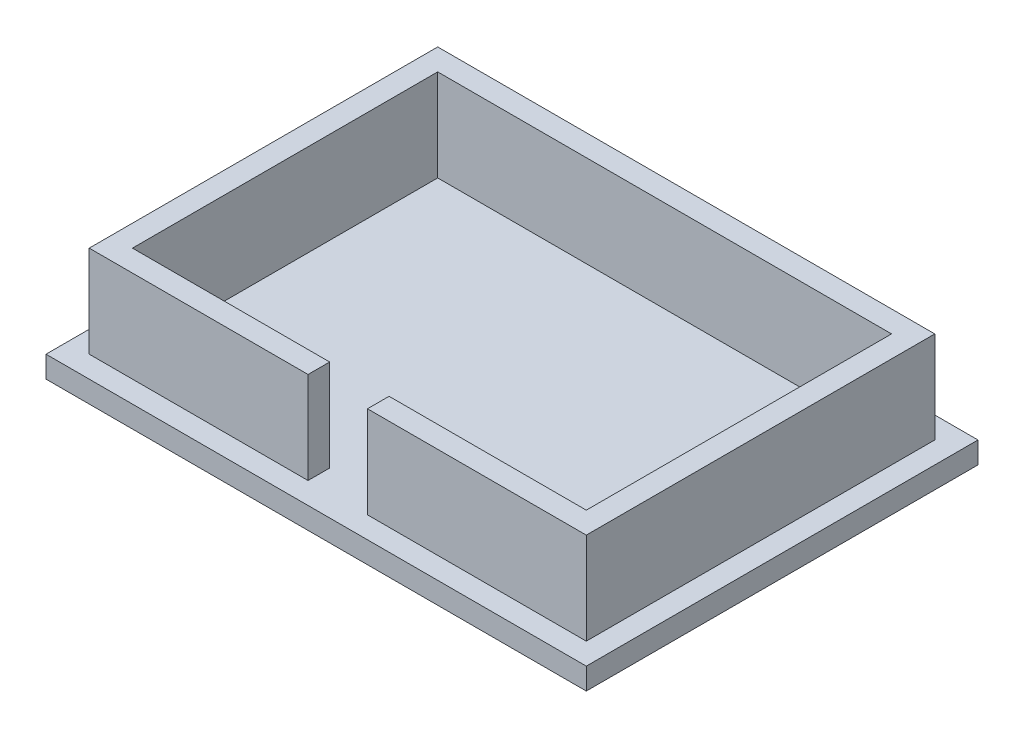
from build123d import *

# Parameters (mm, degrees)
SKETCH2_W           = 100
SKETCH2_H           = 72.5
BOSS_EXTRUDE1_DEPTH = 4
SKETCH2_3_W         = 92
SKETCH2_3_H         = 64.5
SKETCH2_3_W_2       = 84
SKETCH2_3_H_2       = 56.5
BOSS_EXTRUDE2_DEPTH = 21
SKETCH3_W           = 11
SKETCH3_H           = 17
CUT_EXTRUDE1_DEPTH  = 10


with BuildPart() as part:
    # Sketch2 → Boss-Extrude1 (new body)
    with BuildSketch(Plane(origin=(0, 0, 0), x_dir=(1, 0, 0), z_dir=(0, 1, 0))):
        with Locations((3.029157667, 1.037257019)):
            Rectangle(SKETCH2_W, SKETCH2_H)
    extrude(amount=BOSS_EXTRUDE1_DEPTH)

    # Sketch2_3 → Boss-Extrude2 (add)
    with BuildSketch(Plane(origin=(0, 0, 0), x_dir=(1, 0, 0), z_dir=(0, 1, 0))):
        with Locations((3.029157667, 1.037257019)):
            Rectangle(SKETCH2_3_W, SKETCH2_3_H)
        with Locations((3.029157667, 1.037257019)):
            Rectangle(SKETCH2_3_W_2, SKETCH2_3_H_2, mode=Mode.SUBTRACT)
    extrude(amount=BOSS_EXTRUDE2_DEPTH)

    # Sketch3 → Cut-Extrude1 (cut)
    with BuildSketch(Plane.XY.offset(31.212742981)):
        with Locations((3.029157667, 12.5)):
            Rectangle(SKETCH3_W, SKETCH3_H)
    extrude(amount=-CUT_EXTRUDE1_DEPTH, mode=Mode.SUBTRACT)


solid = part.part
